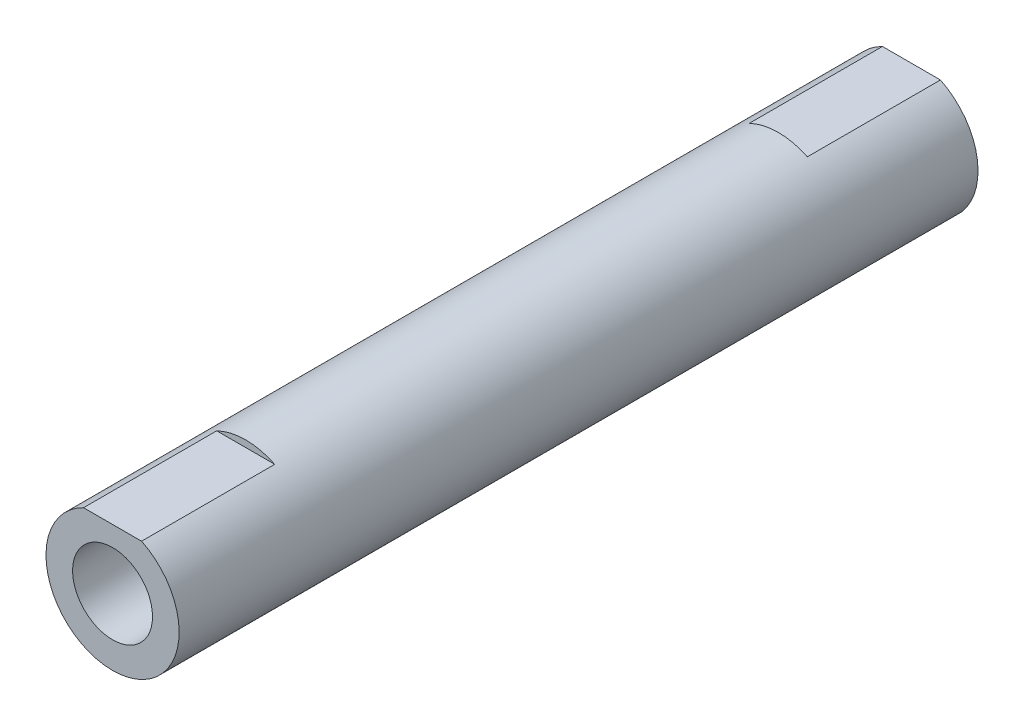
from build123d import *

# Parameters (mm, degrees)
SKETCH1_R           = 5
SKETCH1_R_2         = 3
BOSS_EXTRUDE2_DEPTH = 30
CUT_EXTRUDE9_DEPTH  = 10


with BuildPart() as part:
    # Sketch1 → Boss-Extrude2 (new body, symmetric)
    with BuildSketch(Plane.XY):
        Circle(SKETCH1_R)
        Circle(SKETCH1_R_2, mode=Mode.SUBTRACT)
    extrude(amount=BOSS_EXTRUDE2_DEPTH, both=True)

    # Sketch7 → Cut-Extrude9 (cut)
    with BuildSketch(Plane(origin=(0, 0, -30), x_dir=(-1, 0, 0), z_dir=(0, 0, -1))):
        with BuildLine():
            Line((-2.179449472, 4.5), (2.179449472, 4.5))
            ThreePointArc((2.179449472, 4.5), (0, 5), (-2.179449472, 4.5))
        make_face()
    cut_extrude9 = extrude(amount=-CUT_EXTRUDE9_DEPTH, mode=Mode.SUBTRACT)

    # Mirror2: Cut-Extrude9 across plane
    add(cut_extrude9.mirror(Plane.XY), mode=Mode.SUBTRACT)


solid = part.part
